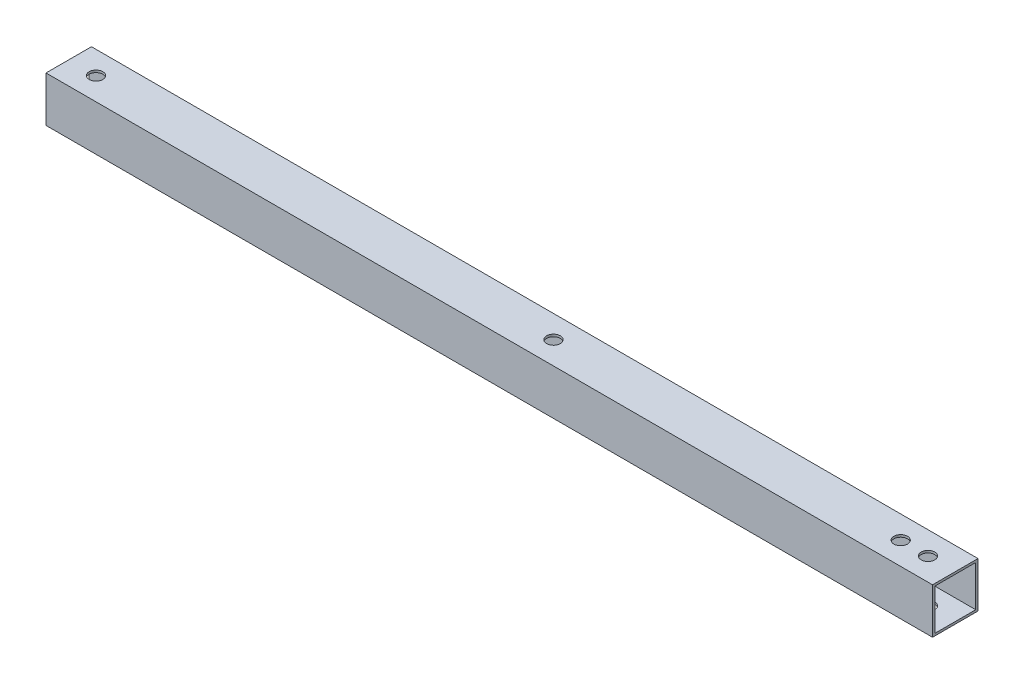
from build123d import *

# Parameters (mm, degrees)
SKETCH2_W           = 20
SKETCH2_H           = 20
SKETCH2_W_2         = 18
SKETCH2_H_2         = 18
BOSS_EXTRUDE1_DEPTH = 390
SKETCH3_R           = 3
CUT_EXTRUDE1_DEPTH  = 1240


with BuildPart() as part:
    # Sketch2 → Boss-Extrude1 (new body)
    with BuildSketch(Plane(origin=(0, 0, 0), x_dir=(0, 0, -1), z_dir=(1, 0, 0))):
        Rectangle(SKETCH2_W, SKETCH2_H)
        Rectangle(SKETCH2_W_2, SKETCH2_H_2, mode=Mode.SUBTRACT)
    extrude(amount=BOSS_EXTRUDE1_DEPTH)

    # Sketch3 → Cut-Extrude1 (cut)
    with BuildSketch(Plane(origin=(0, 10, 0), x_dir=(1, 0, 0), z_dir=(0, 1, 0))):
        with Locations((12, 0)):
            Circle(SKETCH3_R)
        with Locations((213.25, 0)):
            Circle(SKETCH3_R)
        with Locations((378, 0)):
            Circle(SKETCH3_R)
        with Locations((366, 0)):
            Circle(SKETCH3_R)
    extrude(amount=-CUT_EXTRUDE1_DEPTH, mode=Mode.SUBTRACT)


solid = part.part
